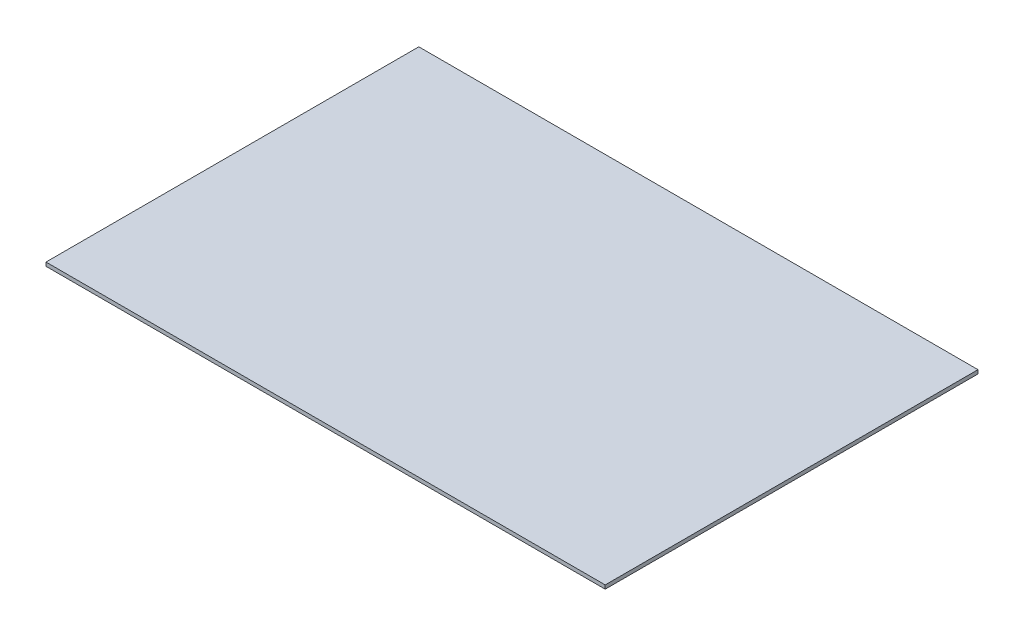
from build123d import *

# Parameters (mm, degrees)
ESQUISSE1_W      = 1500
ESQUISSE1_H      = 1000
EXTRUSION1_DEPTH = 10


with BuildPart() as part:
    # Esquisse1 → Extrusion1 (new body)
    with BuildSketch(Plane(origin=(0, 0, 0), x_dir=(1, 0, 0), z_dir=(0, 1, 0))):
        with Locations((750, 500)):
            Rectangle(ESQUISSE1_W, ESQUISSE1_H)
    extrude(amount=EXTRUSION1_DEPTH)


solid = part.part
